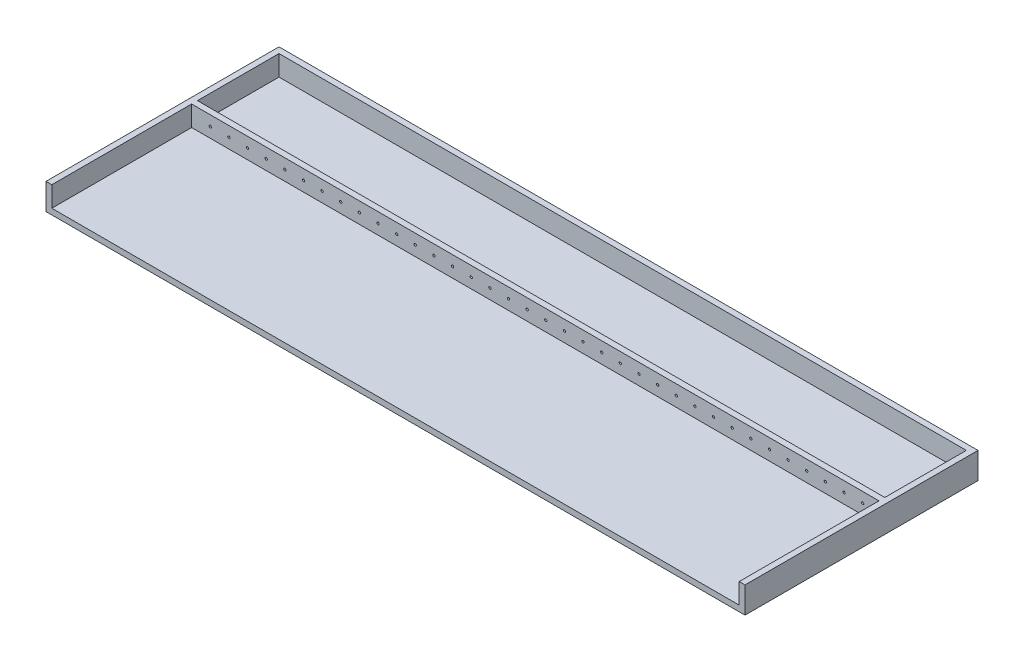
from build123d import *

# Parameters (mm, degrees)
SKETCH1_W           = 600
SKETCH1_H           = 200
BOSS_EXTRUDE1_DEPTH = 5
SKETCH2_W           = 590
SKETCH2_H           = 70
BOSS_EXTRUDE2_DEPTH = 17.5
SKETCH3_R           = 1
CUT_EXTRUDE1_DEPTH  = 5


with BuildPart() as part:
    # Sketch1 → Boss-Extrude1 (new body)
    with BuildSketch(Plane(origin=(0, 0, 0), x_dir=(1, 0, 0), z_dir=(0, 1, 0))):
        with Locations((300, 100)):
            Rectangle(SKETCH1_W, SKETCH1_H)
    extrude(amount=BOSS_EXTRUDE1_DEPTH)

    # Sketch2 → Boss-Extrude2 (add)
    with BuildSketch(Plane(origin=(0, 5, 0), x_dir=(1, 0, 0), z_dir=(0, 1, 0))):
        Polygon((0, 200), (5, 200), (595, 200), (600, 200), (600, 0), (595, 0), (595, 120), (5, 120), (5, 0), (0, 0), align=None)
        with Locations((300, 160)):
            Rectangle(SKETCH2_W, SKETCH2_H, mode=Mode.SUBTRACT)
    extrude(amount=BOSS_EXTRUDE2_DEPTH)

    # Sketch3 → Cut-Extrude1 (cut)
    with BuildSketch(Plane.XY.offset(-120)):
        with Locations((21, 13.75)):
            Circle(SKETCH3_R)
        with Locations((37, 13.75)):
            Circle(SKETCH3_R)
        with Locations((53, 13.75)):
            Circle(SKETCH3_R)
        with Locations((69, 13.75)):
            Circle(SKETCH3_R)
        with Locations((85, 13.75)):
            Circle(SKETCH3_R)
        with Locations((101, 13.75)):
            Circle(SKETCH3_R)
        with Locations((117, 13.75)):
            Circle(SKETCH3_R)
        with Locations((133, 13.75)):
            Circle(SKETCH3_R)
        with Locations((149, 13.75)):
            Circle(SKETCH3_R)
        with Locations((165, 13.75)):
            Circle(SKETCH3_R)
        with Locations((181, 13.75)):
            Circle(SKETCH3_R)
        with Locations((197, 13.75)):
            Circle(SKETCH3_R)
        with Locations((213, 13.75)):
            Circle(SKETCH3_R)
        with Locations((229, 13.75)):
            Circle(SKETCH3_R)
        with Locations((245, 13.75)):
            Circle(SKETCH3_R)
        with Locations((261, 13.75)):
            Circle(SKETCH3_R)
        with Locations((277, 13.75)):
            Circle(SKETCH3_R)
        with Locations((293, 13.75)):
            Circle(SKETCH3_R)
        with Locations((309, 13.75)):
            Circle(SKETCH3_R)
        with Locations((325, 13.75)):
            Circle(SKETCH3_R)
        with Locations((341, 13.75)):
            Circle(SKETCH3_R)
        with Locations((357, 13.75)):
            Circle(SKETCH3_R)
        with Locations((373, 13.75)):
            Circle(SKETCH3_R)
        with Locations((389, 13.75)):
            Circle(SKETCH3_R)
        with Locations((405, 13.75)):
            Circle(SKETCH3_R)
        with Locations((421, 13.75)):
            Circle(SKETCH3_R)
        with Locations((437, 13.75)):
            Circle(SKETCH3_R)
        with Locations((453, 13.75)):
            Circle(SKETCH3_R)
        with Locations((469, 13.75)):
            Circle(SKETCH3_R)
        with Locations((485, 13.75)):
            Circle(SKETCH3_R)
        with Locations((501, 13.75)):
            Circle(SKETCH3_R)
        with Locations((517, 13.75)):
            Circle(SKETCH3_R)
        with Locations((533, 13.75)):
            Circle(SKETCH3_R)
        with Locations((549, 13.75)):
            Circle(SKETCH3_R)
        with Locations((565, 13.75)):
            Circle(SKETCH3_R)
        with Locations((581, 13.75)):
            Circle(SKETCH3_R)
    extrude(amount=-CUT_EXTRUDE1_DEPTH, mode=Mode.SUBTRACT)


solid = part.part
